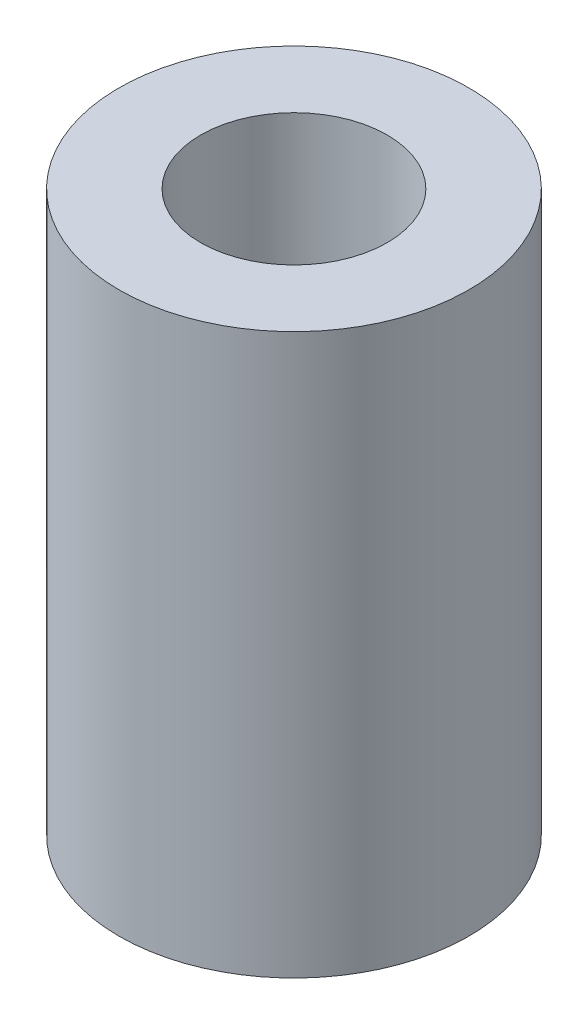
from build123d import *

# Parameters (mm, degrees)
SKETCH1_R           = 7.5
SKETCH1_R_2         = 4
BOSS_EXTRUDE1_DEPTH = 24


with BuildPart() as part:
    # Sketch1 → Boss-Extrude1 (new body)
    with BuildSketch(Plane(origin=(0, 0, 0), x_dir=(1, 0, 0), z_dir=(0, 1, 0))):
        Circle(SKETCH1_R)
        Circle(SKETCH1_R_2, mode=Mode.SUBTRACT)
    extrude(amount=BOSS_EXTRUDE1_DEPTH)


solid = part.part
